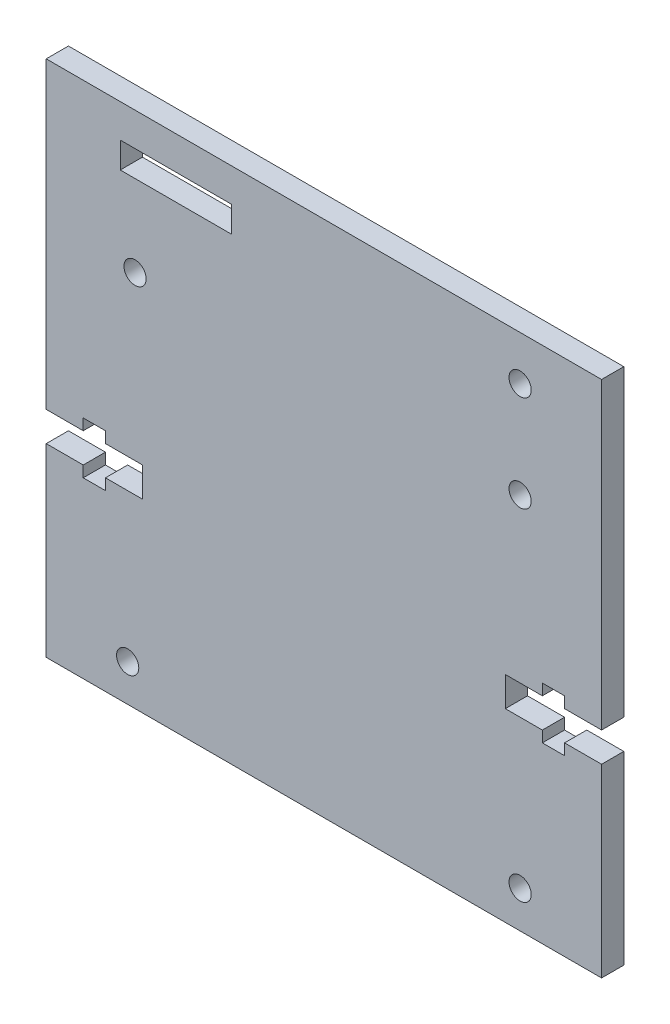
from build123d import *

# Parameters (mm, degrees)
ESQUISSE1_R        = 1.5
ESQUISSE1_W        = 15
ESQUISSE1_H        = 3.5
BOSS_EXTRU_1_DEPTH = 3


with BuildPart() as part:
    # Esquisse1 → Boss.-Extru.1 (new body)
    with BuildSketch(Plane.XY):
        Polygon((-37.5, -21.774747117), (-37.5, -46.774747117), (37.5, -46.774747117), (37.5, -21.774747117), (32.5, -21.774747117), (32.5, -23.274747117), (29.5, -23.274747117), (29.5, -21.774747117), (24.5, -21.774747117), (24.5, -17.774747117), (29.5, -17.774747117), (29.5, -16.274747117), (32.5, -16.274747117), (32.5, -17.774747117), (37.5, -17.774747117), (37.5, 23.225252883), (-37.5, 23.225252883), (-37.5, -17.774747117), (-32.5, -17.774747117), (-32.5, -16.274747117), (-29.5, -16.274747117), (-29.5, -17.774747117), (-24.5, -17.774747117), (-24.5, -21.774747117), (-29.5, -21.774747117), (-29.5, -23.274747117), (-32.5, -23.274747117), (-32.5, -21.774747117), align=None)
        with Locations((-26.5, -41.774747117)):
            Circle(ESQUISSE1_R, mode=Mode.SUBTRACT)
        with Locations((26.5, -41.774747117)):
            Circle(ESQUISSE1_R, mode=Mode.SUBTRACT)
        with Locations((-25.5, 4.225252883)):
            Circle(ESQUISSE1_R, mode=Mode.SUBTRACT)
        with Locations((-20, 16.975252883)):
            Rectangle(ESQUISSE1_W, ESQUISSE1_H, mode=Mode.SUBTRACT)
        with Locations((26.5, 4.225252883)):
            Circle(ESQUISSE1_R, mode=Mode.SUBTRACT)
        with Locations((26.5, 17.225252883)):
            Circle(ESQUISSE1_R, mode=Mode.SUBTRACT)
    extrude(amount=BOSS_EXTRU_1_DEPTH)


solid = part.part
